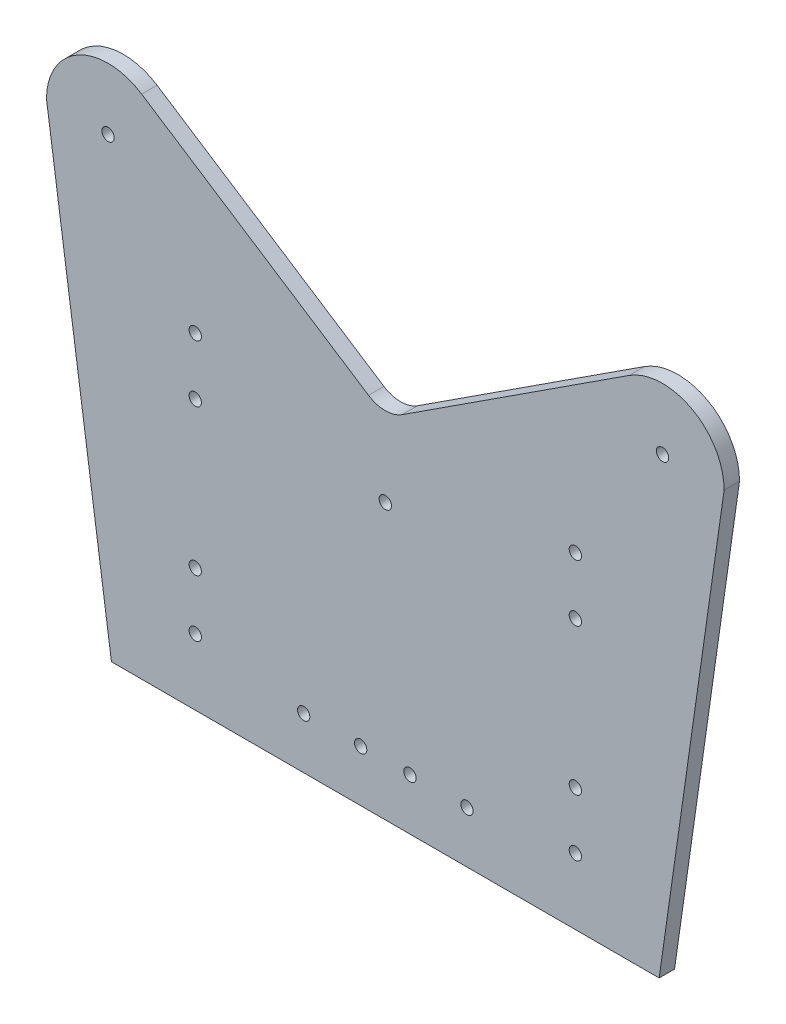
from build123d import *

# Parameters (mm, degrees)
SKETCH_1_R      = 2
EXTRUDE_1_DEPTH = 5


with BuildPart() as part:
    # 草图1 → 凸台-拉伸1 (new body)
    with BuildSketch(Plane.XY):
        with BuildLine():
            Line((-110, 147.74), (-88.912084744, 0))
            Line((-88.912084744, 0), (88.912084744, 0))
            Line((88.912084744, 0), (110, 147.74))
            ThreePointArc((110, 147.74), (99.541573939, 165.317211576), (79.104163323, 164.511426389))
            Line((79.104163323, 164.511426389), (5.447918339, 116.65941923))
            ThreePointArc((5.447918339, 116.65941923), (0, 115.045132425), (-5.447918339, 116.65941923))
            Line((-5.447918339, 116.65941923), (-79.104163323, 164.511426389))
            ThreePointArc((-79.104163323, 164.511426389), (-99.541573939, 165.317211576), (-110, 147.74))
        make_face()
        with Locations((61.7, 105.973140904)):
            Circle(SKETCH_1_R, mode=Mode.SUBTRACT)
        with Locations((-61.7, 21.473140904)):
            Circle(SKETCH_1_R, mode=Mode.SUBTRACT)
        with Locations((-61.7, 39.973140904)):
            Circle(SKETCH_1_R, mode=Mode.SUBTRACT)
        with Locations((-26.5, 16.7)):
            Circle(SKETCH_1_R, mode=Mode.SUBTRACT)
        with Locations((-8, 16.7)):
            Circle(SKETCH_1_R, mode=Mode.SUBTRACT)
        with Locations((8, 16.7)):
            Circle(SKETCH_1_R, mode=Mode.SUBTRACT)
        with Locations((26.5, 16.7)):
            Circle(SKETCH_1_R, mode=Mode.SUBTRACT)
        with Locations((-61.7, 87.473140904)):
            Circle(SKETCH_1_R, mode=Mode.SUBTRACT)
        with Locations((-61.7, 105.973140904)):
            Circle(SKETCH_1_R, mode=Mode.SUBTRACT)
        with Locations((-90, 147.74)):
            Circle(SKETCH_1_R, mode=Mode.SUBTRACT)
        with Locations((0, 89.27)):
            Circle(SKETCH_1_R, mode=Mode.SUBTRACT)
        with Locations((90, 147.74)):
            Circle(SKETCH_1_R, mode=Mode.SUBTRACT)
        with Locations((61.7, 87.473140904)):
            Circle(SKETCH_1_R, mode=Mode.SUBTRACT)
        with Locations((61.7, 39.973140904)):
            Circle(SKETCH_1_R, mode=Mode.SUBTRACT)
        with Locations((61.7, 21.473140904)):
            Circle(SKETCH_1_R, mode=Mode.SUBTRACT)
    extrude(amount=EXTRUDE_1_DEPTH)


solid = part.part
